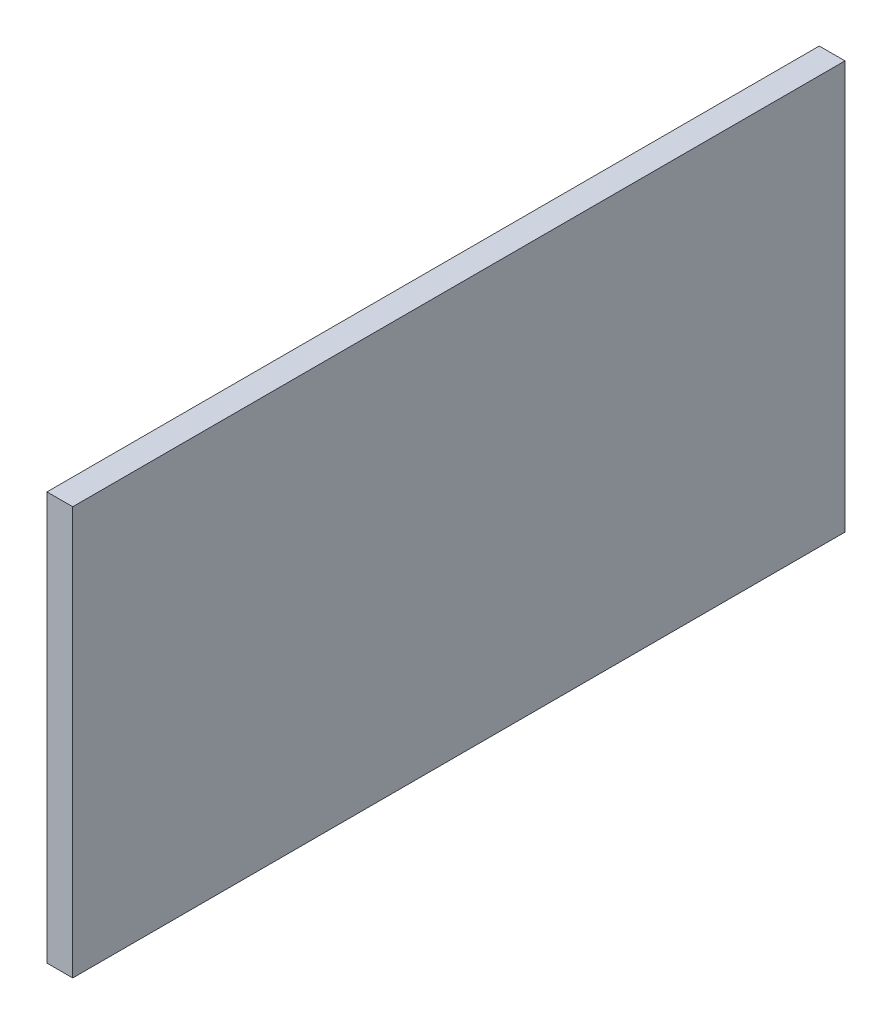
from build123d import *

# Parameters (mm, degrees)
SKETCH1_W           = 375
SKETCH1_H           = 198.17
BOSS_EXTRUDE1_DEPTH = 12.5


with BuildPart() as part:
    # Sketch1 → Boss-Extrude1 (new body)
    with BuildSketch(Plane(origin=(0, 0, 0), x_dir=(0, 0, -1), z_dir=(1, 0, 0))):
        Rectangle(SKETCH1_W, SKETCH1_H)
    extrude(amount=BOSS_EXTRUDE1_DEPTH)


solid = part.part
